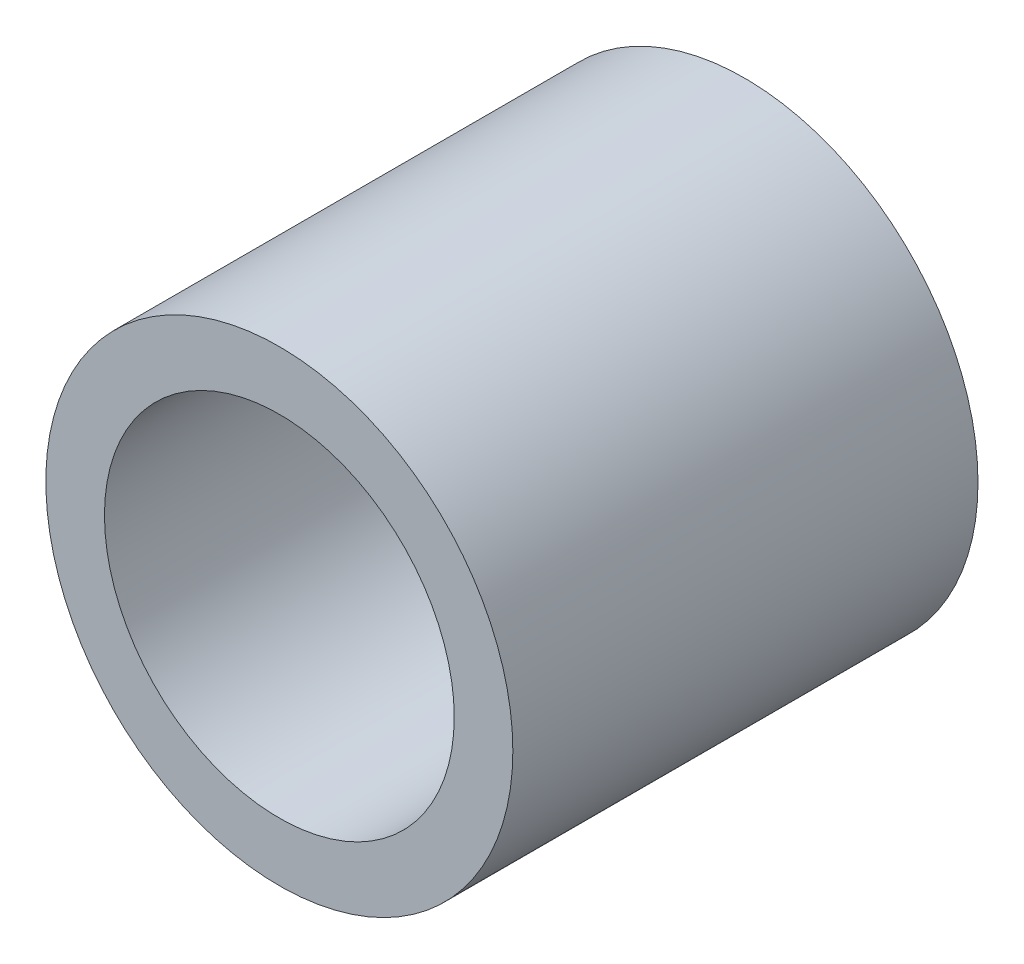
from build123d import *

# Parameters (mm, degrees)
SKETCH1_R      = 6.3754
SKETCH1_R_2    = 4.7752
EXTRUDE1_DEPTH = 6.35


with BuildPart() as part:
    # Sketch1 → Extrude1 (new body, symmetric)
    with BuildSketch(Plane.XY):
        Circle(SKETCH1_R)
        Circle(SKETCH1_R_2, mode=Mode.SUBTRACT)
    extrude(amount=EXTRUDE1_DEPTH, both=True)


solid = part.part
